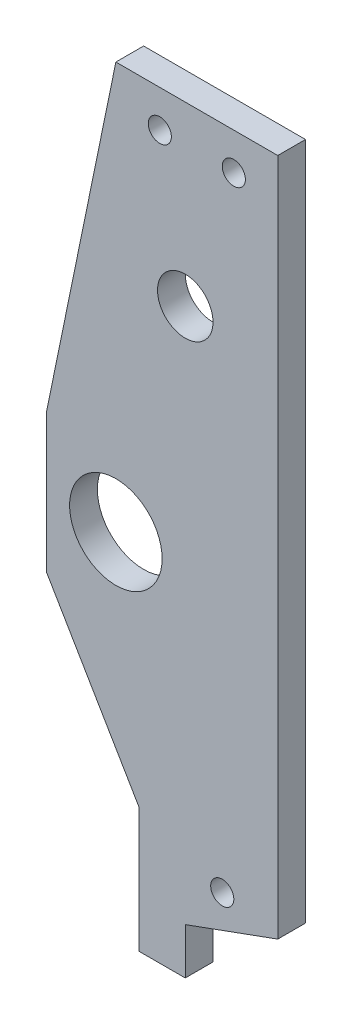
from build123d import *

# Parameters (mm, degrees)
SKETCH2_W           = 20
SKETCH2_H           = 77
BOSS_EXTRUDE1_DEPTH = 3
SKETCH3_W           = 15
SKETCH3_H           = 15
BOSS_EXTRUDE2_DEPTH = 3
BOSS_EXTRUDE3_DEPTH = 3
BOSS_EXTRUDE4_DEPTH = 3
SKETCH6_R           = 5
SKETCH6_R_2         = 3
SKETCH6_R_3         = 1.25
CUT_EXTRUDE1_DEPTH  = 4
SKETCH7_R           = 1.25
CUT_EXTRUDE2_DEPTH  = 10


with BuildPart() as part:
    # Sketch2 → Boss-Extrude1 (new body)
    with BuildSketch(Plane.XY):
        with Locations((-46.024750416, 11.319675541)):
            Rectangle(SKETCH2_W, SKETCH2_H)
    extrude(amount=BOSS_EXTRUDE1_DEPTH)

    # Sketch3 → Boss-Extrude2 (add)
    with BuildSketch(Plane.XY.offset(3)):
        with Locations((-63.524750416, 5.819675541)):
            Rectangle(SKETCH3_W, SKETCH3_H)
    extrude(amount=-BOSS_EXTRUDE2_DEPTH)

    # Sketch4 → Boss-Extrude3 (add)
    with BuildSketch(Plane.XY.offset(3)):
        Polygon((-71.024750416, 13.319675541), (-63.524750416, 49.819675541), (-56.024750416, 49.819675541), (-56.024750416, 13.319675541), align=None)
        Polygon((-71.024750416, -1.680324459), (-56.024750416, -27.180324459), (-56.024750416, -1.680324459), align=None)
    extrude(amount=-BOSS_EXTRUDE3_DEPTH)

    # Sketch5 → Boss-Extrude4 (add)
    with BuildSketch(Plane.XY.offset(3)):
        Polygon((-56.024750416, -27.180324459), (-56.024750416, -32.180324459), (-61.024750416, -32.180324459), (-61.024750416, -18.680324459), align=None)
    extrude(amount=-BOSS_EXTRUDE4_DEPTH)

    # Sketch6 → Cut-Extrude1 (cut, through all)
    with BuildSketch(Plane.XY.offset(3)):
        with Locations((-63.524750416, 5.819675541)):
            Circle(SKETCH6_R)
        with Locations((-56.024750416, 30.71445411)):
            Circle(SKETCH6_R_2)
        with Locations((-52.024750416, -22.180324459)):
            Circle(SKETCH6_R_3)
        Polygon((-56.024750416, -27.180324459), (-46.024750416, -23.540622117), (-46.024750416, 49.819675541), (-36.024750416, 49.819675541), (-36.024750416, -27.180324459), (-46.024750416, -27.180324459), align=None)
    extrude(amount=-CUT_EXTRUDE1_DEPTH, mode=Mode.SUBTRACT)

    # Sketch7 → Cut-Extrude2 (cut)
    with BuildSketch(Plane.XY.offset(3)):
        with Locations((-58.774750416, 45.819675541)):
            Circle(SKETCH7_R)
        with Locations((-50.774750416, 45.819675541)):
            Circle(SKETCH7_R)
    extrude(amount=-CUT_EXTRUDE2_DEPTH, mode=Mode.SUBTRACT)


solid = part.part
